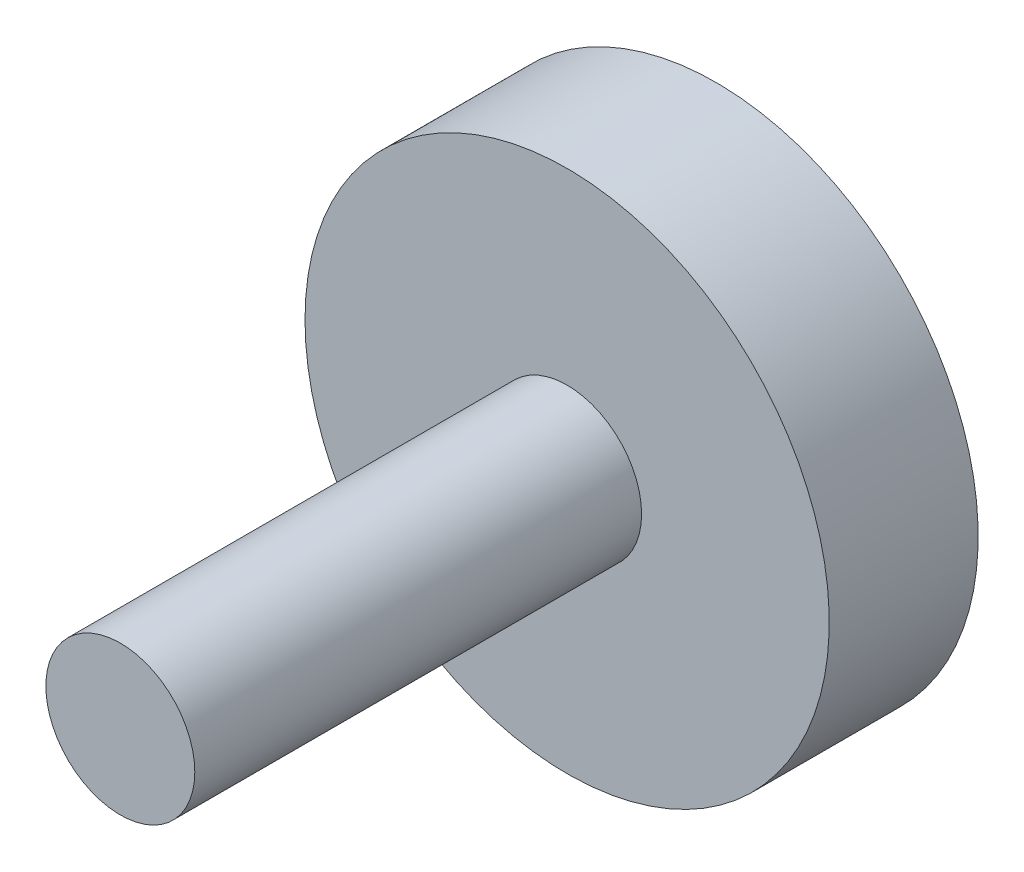
from build123d import *

# Parameters (mm, degrees)
SKETCH1_R           = 5
BOSS_EXTRUDE1_DEPTH = 30
SKETCH2_R           = 17.6
BOSS_EXTRUDE2_DEPTH = 10


with BuildPart() as part:
    # Sketch1 → Boss-Extrude1 (new body)
    with BuildSketch(Plane.XY):
        Circle(SKETCH1_R)
    extrude(amount=BOSS_EXTRUDE1_DEPTH)

    # Sketch2 → Boss-Extrude2 (add)
    with BuildSketch(Plane(origin=(0, 0, 0), x_dir=(-1, 0, 0), z_dir=(0, 0, -1))):
        Circle(SKETCH2_R)
    extrude(amount=BOSS_EXTRUDE2_DEPTH)


solid = part.part
